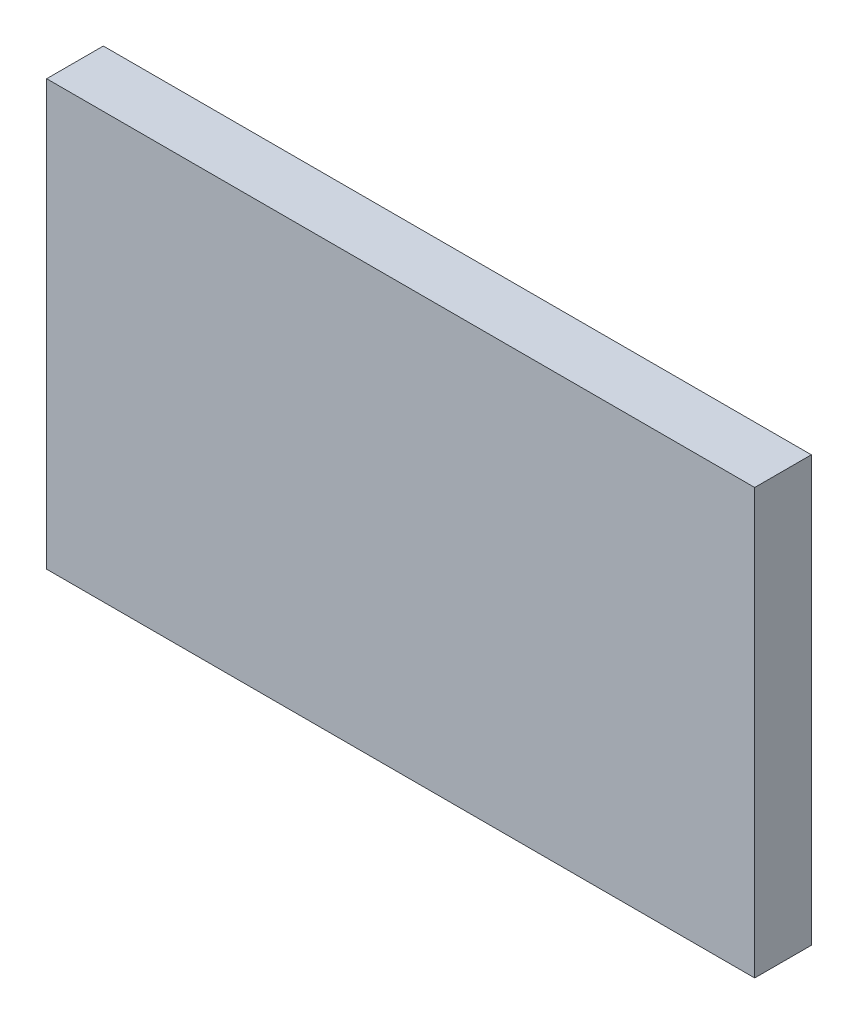
from build123d import *

# Parameters (mm, degrees)
SKETCH2_W           = 200
SKETCH2_H           = 120
BOSS_EXTRUDE1_DEPTH = 16


with BuildPart() as part:
    # Sketch2 → Boss-Extrude1 (new body)
    with BuildSketch(Plane.XY):
        with Locations((100, 60)):
            Rectangle(SKETCH2_W, SKETCH2_H)
    extrude(amount=BOSS_EXTRUDE1_DEPTH)


solid = part.part
